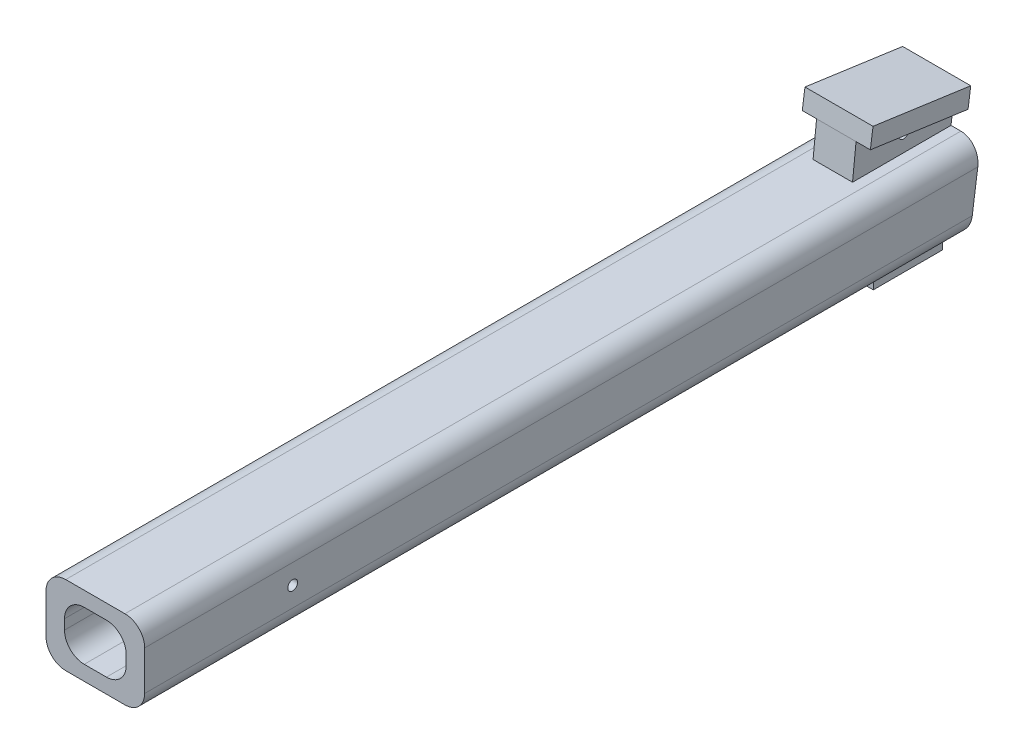
from build123d import *

# Parameters (mm, degrees)
SKETCH1_W                = 20
SKETCH1_H                = 16
SKETCH1_W_2              = 12.5
SKETCH1_H_2              = 10
BOSS_EXTRUDE1_DEPTH      = 170
FILLET1_R                = 4
FILLET2_R                = 4
SKETCH5_R                = 1
CUT_EXTRUDE2_DEPTH       = 21
BOSS_EXTRUDE2_DEPTH      = 4
BOSS_EXTRUDE2_DEPTH_BACK = 4
SKETCH7_W                = 13.8
SKETCH7_H                = 20
BOSS_EXTRUDE3_DEPTH      = 3.9
SKETCH8_R                = 1
CUT_EXTRUDE3_DEPTH       = 17.9
CUT_EXTRUDE4_DEPTH       = 21
SKETCH10_W               = 9
SKETCH10_H               = 14
BOSS_EXTRUDE4_DEPTH      = 4.5
SKETCH11_W               = 5.2
SKETCH11_H               = 3.2
CUT_EXTRUDE5_DEPTH       = 18.353591788
SKETCH12_W               = 1.641339812
SKETCH12_H               = 6.707183576
BOSS_EXTRUDE5_DEPTH      = 2


with BuildPart() as part:
    # Sketch1 → Boss-Extrude1 (new body)
    with BuildSketch(Plane.XY):
        Rectangle(SKETCH1_W, SKETCH1_H)
        Rectangle(SKETCH1_W_2, SKETCH1_H_2, mode=Mode.SUBTRACT)
    extrude(amount=BOSS_EXTRUDE1_DEPTH)

    # Fillet1
    fillet1_edges = [part.edges().sort_by_distance(p)[0] for p in [
        (10, -8, 85),
        (-10, -8, 85),
        (-10, 8, 85),
        (10, 8, 85),
    ]]
    fillet(fillet1_edges, radius=FILLET1_R)

    # Fillet2
    fillet2_edges = [part.edges().sort_by_distance(p)[0] for p in [
        (-6.25, 5, 85),
        (-6.25, -5, 85),
        (6.25, -5, 85),
        (6.25, 5, 85),
    ]]
    fillet(fillet2_edges, radius=FILLET2_R)

    # Sketch5 → Cut-Extrude2 (cut, through all)
    with BuildSketch(Plane.ZY.offset(10)):
        with Locations(Location((140, 0, 0), (0, 0, 270))):  # turned: the seam where the file's is
            Circle(SKETCH5_R)
    extrude(amount=-CUT_EXTRUDE2_DEPTH, mode=Mode.SUBTRACT)

    # Sketch6 → Boss-Extrude2 (add, two sides)
    with BuildSketch(Plane(origin=(0, 0, 0), x_dir=(0, 0, -1), z_dir=(1, 0, 0))) as boss_extrude2_sk:
        Polygon((0, 8), (-20.518331963, 8), (-19.805361375, 14.783462019), (0, 12), align=None)
    extrude(amount=BOSS_EXTRUDE2_DEPTH)
    extrude(boss_extrude2_sk.sketch, amount=-BOSS_EXTRUDE2_DEPTH_BACK)

    # Sketch7 → Boss-Extrude3 (add)
    with BuildSketch(Plane(origin=(0, 11.767570176, -1.653824135), x_dir=(1, 0, 0), z_dir=(0, 0.990268069, -0.139173101))):
        with Locations((0, -11.670077212)):
            Rectangle(SKETCH7_W, SKETCH7_H)
    extrude(amount=BOSS_EXTRUDE3_DEPTH)

    # Sketch8 → Cut-Extrude3 (cut, through all)
    with BuildSketch(Plane.ZY.offset(6.9)):
        with Locations(Location((10.181026889, 11.411194872, 0), (0, 0, 180))):  # turned: the seam where the file's is
            Circle(SKETCH8_R)
    extrude(amount=-CUT_EXTRUDE3_DEPTH, mode=Mode.SUBTRACT)

    # Sketch9 → Cut-Extrude4 (cut, through all)
    with BuildSketch(Plane(origin=(10, 0, 0), x_dir=(0, 0, -1), z_dir=(1, 0, 0))):
        Polygon((0.542775094, 15.862045468), (-3.375840567, -12.020353756), (9.67259421, -8.835863415), (6.237624145, 16.663737896), align=None)
    extrude(amount=-CUT_EXTRUDE4_DEPTH, mode=Mode.SUBTRACT)

    # Sketch10 → Boss-Extrude4 (add)
    with BuildSketch(Plane.XZ.offset(8)):
        with Locations((0, 9.810816694)):
            Rectangle(SKETCH10_W, SKETCH10_H)
    extrude(amount=BOSS_EXTRUDE4_DEPTH)

    # Sketch11 → Cut-Extrude5 (cut, through all)
    with BuildSketch(Plane.XY.offset(16.810816694)):
        with Locations((0, -9.6)):
            Rectangle(SKETCH11_W, SKETCH11_H)
    extrude(amount=-CUT_EXTRUDE5_DEPTH, mode=Mode.SUBTRACT)

    # Sketch12 → Boss-Extrude5 (add)
    with BuildSketch(Plane.XZ.offset(12.5)):
        with Locations((0, 2.810816694)):
            Rectangle(SKETCH12_W, SKETCH12_H)
    extrude(amount=BOSS_EXTRUDE5_DEPTH)


solid = part.part
